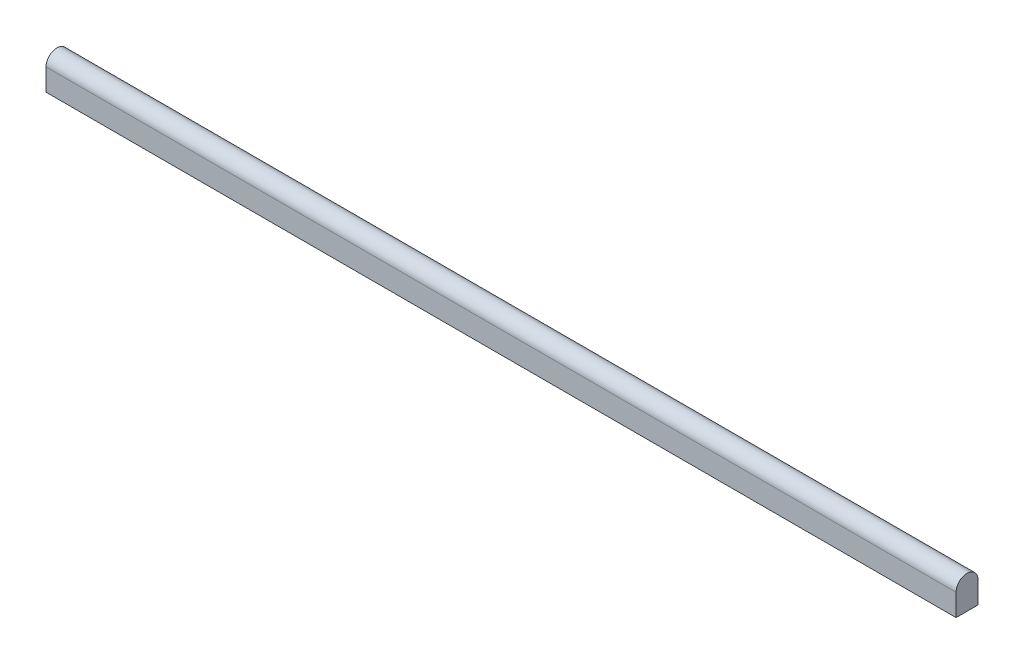
from build123d import *

# Parameters (mm, degrees)
EXTRUSION1_DEPTH        = 166
ENL_V_MAT_EXTRU_2_DEPTH = 10
ESQUISSE4_W             = 10
ESQUISSE4_H             = 1
ENL_V_MAT_EXTRU_3_DEPTH = 2


with BuildPart() as part:
    # Esquisse1 → Extrusion1 (new body)
    with BuildSketch(Plane(origin=(0, 0, 0), x_dir=(0, 0, -1), z_dir=(1, 0, 0))):
        with BuildLine():
            Line((-2, 0), (-2, -4))
            Line((-2, -4), (2, -4))
            Line((2, -4), (2, 0))
            ThreePointArc((2, 0), (0, 2), (-2, 0))
        make_face()
    extrude(amount=EXTRUSION1_DEPTH)

    # Esquisse3 → Enlèv. mat.-Extru.2 (cut)
    with BuildSketch(Plane.ZY):
        with BuildLine():
            Line((-1, 0), (-1, -3))
            Line((-1, -3), (1, -3))
            Line((1, -3), (1, 0))
            ThreePointArc((1, 0), (0, 1), (-1, 0))
        make_face()
    extrude(amount=-ENL_V_MAT_EXTRU_2_DEPTH, mode=Mode.SUBTRACT)

    # Esquisse4 → Enlèv. mat.-Extru.3 (cut)
    with BuildSketch(Plane.XZ.offset(4)):
        with Locations((5, 0)):
            Rectangle(ESQUISSE4_W, ESQUISSE4_H)
    extrude(amount=-ENL_V_MAT_EXTRU_3_DEPTH, mode=Mode.SUBTRACT)


solid = part.part
